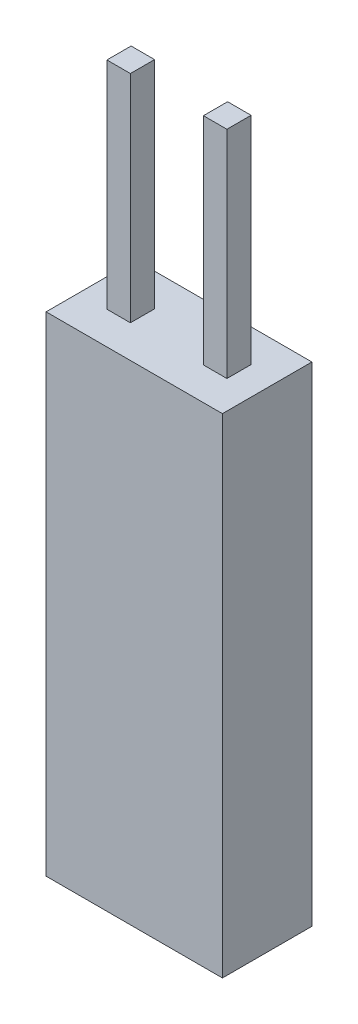
from build123d import *

# Parameters (mm, degrees)
SKETCH1_W           = 5.1054
SKETCH1_H           = 2.5908
BOSS_EXTRUDE1_DEPTH = 14.15
SKETCH2_W           = 0.68
SKETCH2_H           = 0.7
BOSS_EXTRUDE2_DEPTH = 6.25


with BuildPart() as part:
    # Sketch1 → Boss-Extrude1 (new body)
    with BuildSketch(Plane(origin=(0, 0, 0), x_dir=(1, 0, 0), z_dir=(0, 1, 0))):
        Rectangle(SKETCH1_W, SKETCH1_H)
    extrude(amount=-BOSS_EXTRUDE1_DEPTH)

    # Sketch2 → Boss-Extrude2 (add)
    with BuildSketch(Plane(origin=(0, 0, 0), x_dir=(1, 0, 0), z_dir=(0, 1, 0))):
        with Locations((-1.397, 0)):
            Rectangle(SKETCH2_W, SKETCH2_H)
        with Locations((1.397, 0)):
            Rectangle(SKETCH2_W, SKETCH2_H)
    extrude(amount=BOSS_EXTRUDE2_DEPTH)


solid = part.part
